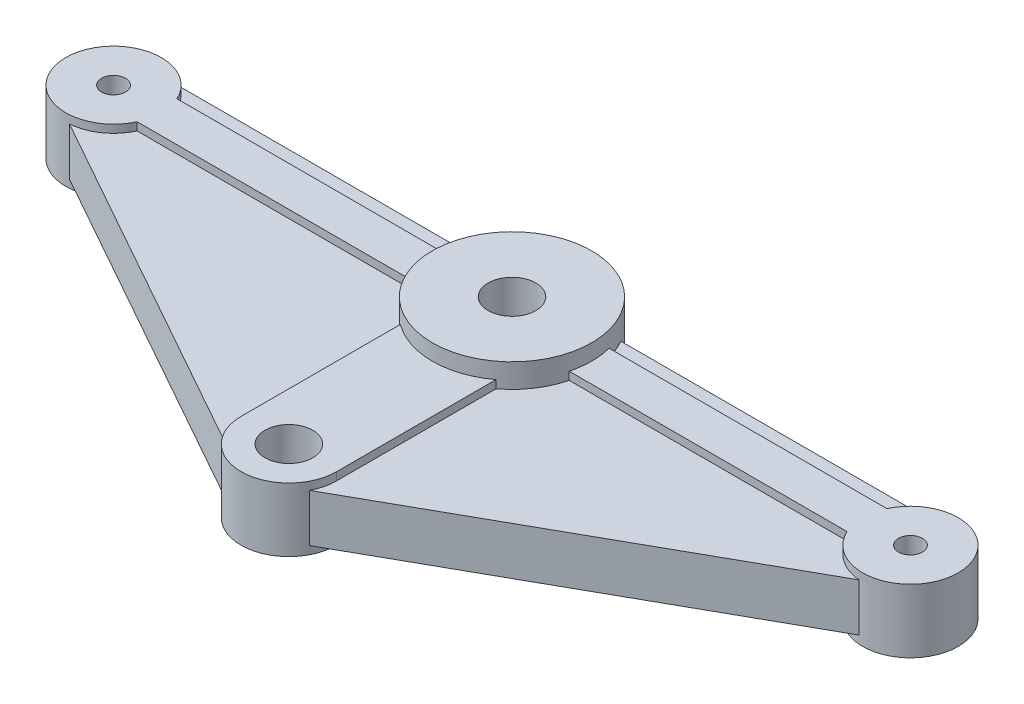
from build123d import *
from build123d.topology import SkipClean

# Parameters (mm, degrees)
SKETCH1_R      = 0.75
SKETCH1_R_2    = 1.5
EXTRUDE1_DEPTH = 1.5
SKETCH2_R      = 0.75
SKETCH2_R_2    = 1.5
EXTRUDE2_DEPTH = 2
SKETCH3_R      = 5
SKETCH3_R_2    = 1.5
EXTRUDE3_DEPTH = 3


with BuildPart() as part:
    # Sketch1 → Extrude1 (new body, symmetric)
    with BuildSketch(Plane(origin=(0, 0, 0), x_dir=(1, 0, 0), z_dir=(0, 1, 0))):
        with BuildLine():
            Line((-25, 2.5), (25, 2.5))
            ThreePointArc((25, 2.5), (27.419004196, 0.631204167), (26.221508422, -2.18126504))
            Line((26.221508422, -2.18126504), (1.221508422, -16.18126504))
            ThreePointArc((1.221508422, -16.18126504), (0, -16.5), (-1.221508422, -16.18126504))
            Line((-1.221508422, -16.18126504), (-26.221508422, -2.18126504))
            ThreePointArc((-26.221508422, -2.18126504), (-27.419004196, 0.631204167), (-25, 2.5))
        make_face()
        with Locations(Location((25, 0, 0), (0, 0, 270))):  # turned: the seam where the file's is
            Circle(SKETCH1_R, mode=Mode.SUBTRACT)
        with Locations(Location((-25, 0, 0), (0, 0, 270))):  # turned: the seam where the file's is
            Circle(SKETCH1_R, mode=Mode.SUBTRACT)
        with Locations(Location((0, -14, 0), (0, 0, 270))):  # turned: the seam where the file's is
            Circle(SKETCH1_R_2, mode=Mode.SUBTRACT)
        with Locations(Location((0, 0, 0), (0, 0, 270))):  # turned: the seam where the file's is
            Circle(SKETCH1_R_2, mode=Mode.SUBTRACT)
    extrude(amount=EXTRUDE1_DEPTH, both=True)

    # Sketch2 → Extrude2 (add, symmetric)
    with SkipClean():  # keep this step's faces unmerged: merging them makes the solid invalid here
        with BuildSketch(Plane(origin=(0, 0, 0), x_dir=(1, 0, 0), z_dir=(0, 1, 0))):
            with BuildLine():
                Line((-22.272821971, 1.25), (-0.829156198, 1.25))
                ThreePointArc((-0.829156198, 1.25), (0, -1.5), (0.829156198, 1.25))
                Line((0.829156198, 1.25), (22.272821971, 1.25))
                ThreePointArc((22.272821971, 1.25), (28, 0), (22.272821971, -1.25))
                Line((22.272821971, -1.25), (3, -1.25))
                Line((3, -1.25), (3, -14))
                ThreePointArc((3, -14), (0, -17), (-3, -14))
                Line((-3, -14), (-3, -1.25))
                Line((-3, -1.25), (-22.272821971, -1.25))
                ThreePointArc((-22.272821971, -1.25), (-28, 0), (-22.272821971, 1.25))
            make_face()
            with Locations(Location((25, 0, 0), (0, 0, 270))):  # turned: the seam where the file's is
                Circle(SKETCH2_R, mode=Mode.SUBTRACT)
            with Locations(Location((0, -14, 0), (0, 0, 270))):  # turned: the seam where the file's is
                Circle(SKETCH2_R_2, mode=Mode.SUBTRACT)
            with Locations(Location((-25, 0, 0), (0, 0, 270))):  # turned: the seam where the file's is
                Circle(SKETCH2_R, mode=Mode.SUBTRACT)
        extrude(amount=EXTRUDE2_DEPTH, both=True)

    # Sketch3 → Extrude3 (add, symmetric)
    with SkipClean():  # keep this step's faces unmerged: merging them makes the solid invalid here
        with BuildSketch(Plane(origin=(0, 0, 0), x_dir=(1, 0, 0), z_dir=(0, 1, 0))):
            with Locations(Location((0, 0, 0), (0, 0, 270))):  # turned: the seam where the file's is
                Circle(SKETCH3_R)
            with Locations(Location((0, 0, 0), (0, 0, 270))):  # turned: the seam where the file's is
                Circle(SKETCH3_R_2, mode=Mode.SUBTRACT)
        extrude(amount=EXTRUDE3_DEPTH, both=True)


solid = part.part
